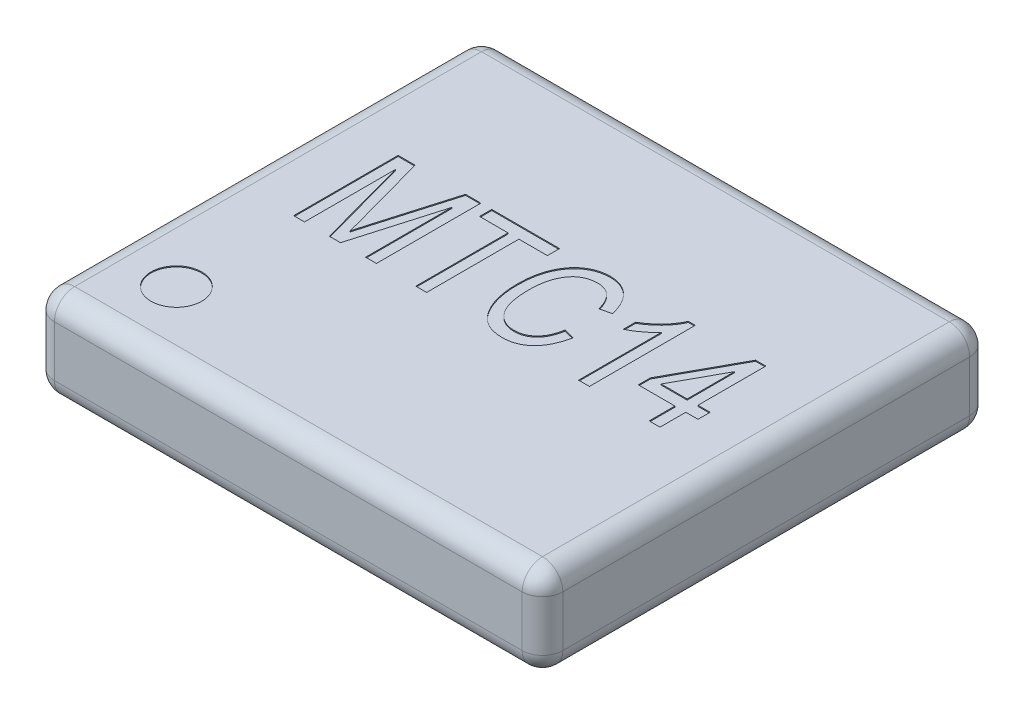
from build123d import *

# Parameters (mm, degrees)
SKETCH1_W           = 5
SKETCH1_H           = 4.4
BOSS_EXTRUDE1_DEPTH = 0.45
FILLET1_R           = 0.2
SKETCH2_R           = 0.25
CUT_EXTRUDE1_DEPTH  = 0.01
CUT_EXTRUDE2_DEPTH  = 0.01


with BuildPart() as part:
    # Sketch1 → Boss-Extrude1 (new body, symmetric)
    with BuildSketch(Plane(origin=(0, 0, 0), x_dir=(1, 0, 0), z_dir=(0, 1, 0))):
        Rectangle(SKETCH1_W, SKETCH1_H)
    extrude(amount=BOSS_EXTRUDE1_DEPTH, both=True)

    # Fillet1
    fillet1_edges = [part.edges().sort_by_distance(p)[0] for p in [
        (-2.5, 0.45, 0),
        (0, 0.45, 2.2),
        (2.5, 0.45, 0),
        (0, -0.45, 2.2),
        (-2.5, -0.45, 0),
        (0, -0.45, -2.2),
        (2.5, -0.45, 0),
        (0, 0.45, -2.2),
        (2.5, 0, 2.2),
        (-2.5, 0, 2.2),
        (-2.5, 0, -2.2),
        (2.5, 0, -2.2),
    ]]
    fillet(fillet1_edges, radius=FILLET1_R)

    # Sketch2 → Cut-Extrude1 (cut)
    with BuildSketch(Plane(origin=(0, 0.45, 0), x_dir=(1, 0, 0), z_dir=(0, 1, 0))):
        with Locations((-1.8, -1.5)):
            Circle(SKETCH2_R)
    extrude(amount=-CUT_EXTRUDE1_DEPTH, mode=Mode.SUBTRACT)

    # Sketch3 → Cut-Extrude2 (cut)
    with BuildSketch(Plane(origin=(0, 0.45, 0), x_dir=(1, 0, 0), z_dir=(0, 1, 0))):
        with BuildLine():
            Line((-1.827310363, -0.319706553), (-1.827310363, 0.707620921))
            Line((-1.827310363, 0.707620921), (-1.660327955, 0.707620921))
            Line((-1.660327955, 0.707620921), (-1.460407694, -0.019721927))
            Line((-1.460407694, -0.019721927), (-1.420381948, -0.171903148))
            add(Edge.make_bspline(
                [(-1.420381948, -0.171903148), (-1.419076305, -0.166895981), (-1.416332792, -0.156374551), (-1.411677731, -0.139784549), (-1.406425249, -0.121628852), (-1.401128192, -0.101751366), (-1.395012301, -0.080437003), (-1.388308183, -0.057535448), (-1.381231749, -0.032932814), (-1.3763921, -0.015970427), (-1.373893713, -0.007213881)],
                knots=[0, 0, 0, 0, 1.5523e-05, 3.2619e-05, 5.169e-05, 7.2223e-05, 9.4329e-05, 0.000118211, 0.000143811, 0.000171129, 0.000171129, 0.000171129, 0.000171129], degree=3))
            Line((-1.373893713, -0.007213881), (-1.164592417, 0.707620921))
            Line((-1.164592417, 0.707620921), (-1.013453533, 0.707620921))
            Line((-1.013453533, 0.707620921), (-1.013453533, -0.319706553))
            Line((-1.013453533, -0.319706553), (-1.120188855, -0.319706553))
            Line((-1.120188855, -0.319706553), (-1.120188855, 0.528338935))
            Line((-1.120188855, 0.528338935), (-1.36680582, -0.319706553))
            Line((-1.36680582, -0.319706553), (-1.476042751, -0.319706553))
            Line((-1.476042751, -0.319706553), (-1.720575042, 0.576911846))
            Line((-1.720575042, 0.576911846), (-1.720575042, -0.319706553))
            Line((-1.720575042, -0.319706553), (-1.827310363, -0.319706553))
        make_face()
        Polygon((-0.626537991, -0.319706553), (-0.626537991, 0.587543684), (-0.906718211, 0.587543684), (-0.906718211, 0.707620921), (-0.239622449, 0.707620921), (-0.239622449, 0.587543684), (-0.519802669, 0.587543684), (-0.519802669, -0.319706553), align=None)
        with BuildLine():
            Line((0.480840974, 0.040525159), (0.587576296, 0.013841329))
            add(Edge.make_bspline(
                [(0.587576296, 0.013841329), (0.584395031, -0.000303061), (0.578192893, -0.027878719), (0.566559728, -0.067541525), (0.552966118, -0.104351689), (0.537784313, -0.138448662), (0.520892574, -0.169837676), (0.502374049, -0.198497138), (0.482072855, -0.224403625), (0.459887869, -0.247238117), (0.436559664, -0.267726705), (0.411544879, -0.284924885), (0.3855961, -0.299997515), (0.35821753, -0.312002214), (0.329685518, -0.321510498), (0.299846458, -0.328069758), (0.268821589, -0.332465266), (0.247650883, -0.332852465), (0.236934086, -0.333048468)],
                knots=[0, 0, 0, 0, 4.3486e-05, 8.4779e-05, 0.000123892, 0.000161124, 0.000196662, 0.00023072, 0.000263375, 0.000295221, 0.000326109, 0.000356354, 0.000386142, 0.000416008, 0.000445871, 0.000476216, 0.000507556, 0.000539685, 0.000539685, 0.000539685, 0.000539685], degree=3))
            add(Edge.make_bspline(
                [(0.236934086, -0.333048468), (0.227475616, -0.332917955), (0.208934796, -0.332662119), (0.181649423, -0.329770042), (0.155347424, -0.325545626), (0.130089693, -0.319185676), (0.105820589, -0.311399813), (0.08277443, -0.3014005), (0.060576737, -0.290020597), (0.039481578, -0.276571878), (0.019238325, -0.261336217), (0.000390249, -0.243621602), (-0.017974355, -0.224257512), (-0.034914387, -0.202318667), (-0.051579747, -0.178679736), (-0.066562135, -0.152456863), (-0.081096839, -0.124417237), (-0.094482107, -0.094335396), (-0.10694959, -0.062513838), (-0.117130895, -0.028905318), (-0.126211469, 0.005905242), (-0.133418269, 0.042187644), (-0.139364493, 0.079791147), (-0.143129992, 0.118919841), (-0.145791374, 0.159384296), (-0.146081522, 0.186864677), (-0.146229042, 0.20083661)],
                knots=[0, 0, 0, 0, 2.8364e-05, 5.56e-05, 8.2229e-05, 0.000108217, 0.000133664, 0.000158601, 0.000183496, 0.000208422, 0.000233564, 0.000259381, 0.00028593, 0.000313539, 0.000342453, 0.000372629, 0.00040405, 0.000437176, 0.000471361, 0.000506505, 0.000542455, 0.00057925, 0.000617432, 0.000656616, 0.000697136, 0.000739046, 0.000739046, 0.000739046, 0.000739046], degree=3))
            add(Edge.make_bspline(
                [(-0.146229042, 0.20083661), (-0.146082726, 0.214600213), (-0.145795755, 0.241594929), (-0.143138731, 0.281226507), (-0.139382813, 0.319317698), (-0.133415638, 0.355737764), (-0.126258137, 0.390645184), (-0.11721146, 0.423807645), (-0.106877802, 0.455497973), (-0.094589841, 0.485413106), (-0.080742895, 0.513576884), (-0.065946272, 0.540106496), (-0.050165676, 0.565004349), (-0.033039905, 0.588015389), (-0.014660392, 0.609082481), (0.004823693, 0.628416597), (0.025513523, 0.645897485), (0.047169702, 0.661841465), (0.069863398, 0.675659991), (0.09312658, 0.687931616), (0.117134252, 0.698113757), (0.141798797, 0.70648085), (0.167096376, 0.712984833), (0.19303652, 0.717456636), (0.219553904, 0.720610709), (0.237480568, 0.720844767), (0.246523588, 0.720962837)],
                knots=[0, 0, 0, 0, 4.1285e-05, 8.0973e-05, 0.00011912, 0.000156066, 0.000191636, 0.000225973, 0.000259133, 0.000291574, 0.0003229, 0.000353232, 0.000382667, 0.000411269, 0.000439195, 0.000466466, 0.000493533, 0.000520385, 0.000547058, 0.000573166, 0.000599225, 0.0006252, 0.000651239, 0.000677492, 0.000704128, 0.000731242, 0.000731242, 0.000731242, 0.000731242], degree=3))
            add(Edge.make_bspline(
                [(0.246523588, 0.720962837), (0.256399867, 0.720707142), (0.275800232, 0.72020487), (0.304455466, 0.716687579), (0.331867412, 0.710290448), (0.358497176, 0.702048799), (0.383845023, 0.690907518), (0.408238459, 0.677503731), (0.431464727, 0.661554923), (0.453538992, 0.643159328), (0.47443729, 0.622544653), (0.493686239, 0.599494947), (0.51111012, 0.574112399), (0.527386091, 0.546752405), (0.541404415, 0.516748103), (0.554043819, 0.484627148), (0.565551692, 0.45033469), (0.571291551, 0.426380245), (0.574234381, 0.414098786)],
                knots=[0, 0, 0, 0, 2.9629e-05, 5.8201e-05, 8.642e-05, 0.000113979, 0.000141708, 0.000169327, 0.000197371, 0.000226091, 0.000255426, 0.000285321, 0.000316028, 0.000347705, 0.000380715, 0.000415246, 0.00045124, 0.00048911, 0.00048911, 0.00048911, 0.00048911], degree=3))
            Line((0.574234381, 0.414098786), (0.467499059, 0.387414956))
            add(Edge.make_bspline(
                [(0.467499059, 0.387414956), (0.465086623, 0.396058664), (0.460381649, 0.412916493), (0.452009013, 0.437129474), (0.442851654, 0.459689261), (0.432899367, 0.48065676), (0.421816688, 0.499850026), (0.409927535, 0.517425469), (0.397211558, 0.533432015), (0.383401667, 0.547532153), (0.368957475, 0.560254416), (0.353436366, 0.571153015), (0.33696721, 0.580257787), (0.31969883, 0.587911456), (0.301576655, 0.59366838), (0.282541097, 0.597908778), (0.26264275, 0.600409981), (0.249032163, 0.600725806), (0.242145772, 0.600885599)],
                knots=[0, 0, 0, 0, 2.6917e-05, 5.2497e-05, 7.6808e-05, 9.9932e-05, 0.000122066, 0.000143228, 0.000163544, 0.000183299, 0.000202361, 0.000221215, 0.000240066, 0.000258736, 0.000277788, 0.000297008, 0.000317177, 0.000337832, 0.000337832, 0.000337832, 0.000337832], degree=3))
            add(Edge.make_bspline(
                [(0.242145772, 0.600885599), (0.228553394, 0.600382016), (0.202029929, 0.599399348), (0.163668963, 0.59122538), (0.127976249, 0.578150807), (0.10081036, 0.562462112), (0.080668467, 0.547414308), (0.06639154, 0.53454959), (0.052948565, 0.520187763), (0.04017589, 0.50446559), (0.028076929, 0.487254475), (0.017166223, 0.468344891), (0.006584779, 0.448273298), (-0.002950233, 0.426611249), (-0.011444648, 0.403477857), (-0.018999922, 0.378923185), (-0.025443752, 0.352903777), (-0.030641652, 0.325340437), (-0.034506458, 0.296311096), (-0.037486201, 0.265791874), (-0.0390862, 0.233791654), (-0.039356213, 0.21195644), (-0.03949372, 0.20083661)],
                knots=[0, 0, 0, 0, 4.0741e-05, 7.9501e-05, 0.0001171, 0.00015436, 0.000173122, 0.00019246, 0.000211927, 0.000232081, 0.00025319, 0.000274963, 0.000297528, 0.000321235, 0.000345903, 0.000371422, 0.00039827, 0.000426276, 0.000455523, 0.000486099, 0.000518246, 0.000551607, 0.000551607, 0.000551607, 0.000551607], degree=3))
            add(Edge.make_bspline(
                [(-0.03949372, 0.20083661), (-0.039230056, 0.184153986), (-0.038718658, 0.151796805), (-0.035457789, 0.104803624), (-0.029752713, 0.060977715), (-0.021377657, 0.020465173), (-0.011032684, -0.016864365), (0.001553577, -0.05102518), (0.016858218, -0.081873852), (0.034343041, -0.109474551), (0.053851982, -0.13380736), (0.074900951, -0.155007767), (0.097622791, -0.17285918), (0.121741534, -0.187702121), (0.147616297, -0.198929118), (0.174883778, -0.20714147), (0.203753117, -0.212013118), (0.22350406, -0.212647171), (0.233598607, -0.212971231)],
                knots=[0, 0, 0, 0, 5.0048e-05, 9.7071e-05, 0.000141237, 0.00018253, 0.000221074, 0.000257355, 0.000291571, 0.000324188, 0.000355182, 0.000384959, 0.00041361, 0.000441676, 0.00046968, 0.000497974, 0.000526933, 0.000557207, 0.000557207, 0.000557207, 0.000557207], degree=3))
            add(Edge.make_bspline(
                [(0.233598607, -0.212971231), (0.241113631, -0.212764544), (0.255922807, -0.212357246), (0.277755588, -0.209314811), (0.298873709, -0.204610327), (0.319223658, -0.197705815), (0.338586266, -0.188605191), (0.357352248, -0.178009704), (0.375133898, -0.165098389), (0.392179853, -0.150409392), (0.408139491, -0.133609023), (0.422729445, -0.114714897), (0.436169816, -0.093880988), (0.447699916, -0.07076297), (0.458184588, -0.045845289), (0.467337125, -0.018898266), (0.475063737, 0.010077945), (0.478884261, 0.030212883), (0.480840974, 0.040525159)],
                knots=[0, 0, 0, 0, 2.2539e-05, 4.4415e-05, 6.6009e-05, 8.7369e-05, 0.000108728, 0.000130112, 0.000151922, 0.000174534, 0.000197538, 0.000221307, 0.000246057, 0.000271789, 0.000298698, 0.000327111, 0.000357097, 0.000388578, 0.000388578, 0.000388578, 0.000388578], degree=3))
        make_face()
        with BuildLine():
            Line((1.08122716, -0.319706553), (0.974491838, -0.319706553))
            Line((0.974491838, -0.319706553), (0.974491838, 0.494150278))
            add(Edge.make_bspline(
                [(0.974491838, 0.494150278), (0.967936832, 0.486604904), (0.95435159, 0.470967124), (0.930768305, 0.448728022), (0.90448734, 0.425794971), (0.875390822, 0.40354181), (0.845743786, 0.382226883), (0.816461828, 0.363480033), (0.788642424, 0.347168861), (0.76997953, 0.338302985), (0.761021194, 0.334047295)],
                knots=[0, 0, 0, 0, 2.9968e-05, 6.2108e-05, 9.7134e-05, 0.000134579, 0.000171948, 0.000206644, 0.000238862, 0.000268603, 0.000268603, 0.000268603, 0.000268603], degree=3))
            Line((0.761021194, 0.334047295), (0.761021194, 0.454124532))
            add(Edge.make_bspline(
                [(0.761021194, 0.454124532), (0.775417963, 0.462789055), (0.804088224, 0.480043909), (0.844259012, 0.509934889), (0.882207837, 0.542197288), (0.916800417, 0.577169143), (0.947774273, 0.61321989), (0.974359845, 0.649198579), (0.996158331, 0.684722944), (1.006851186, 0.709159608), (1.012015975, 0.720962837)],
                knots=[0, 0, 0, 0, 5.0382e-05, 0.000100333, 0.000150011, 0.000199688, 0.000247737, 0.000292476, 0.000333806, 0.000372419, 0.000372419, 0.000372419, 0.000372419], degree=3))
            Line((1.012015975, 0.720962837), (1.08122716, 0.720962837))
            Line((1.08122716, 0.720962837), (1.08122716, -0.319706553))
        make_face()
        Polygon((1.668271431, -0.319706553), (1.668271431, -0.066210163), (1.308039719, -0.066210163), (1.308039719, 0.053867074), (1.674316986, 0.720962837), (1.775006753, 0.720962837), (1.775006753, 0.053867074), (1.89508399, 0.053867074), (1.89508399, -0.066210163), (1.775006753, -0.066210163), (1.775006753, -0.319706553), align=None)
        Polygon((1.668271431, 0.053867074), (1.668271431, 0.518124031), (1.413315769, 0.053867074), align=None, mode=Mode.SUBTRACT)
    extrude(amount=-CUT_EXTRUDE2_DEPTH, mode=Mode.SUBTRACT)


solid = part.part
